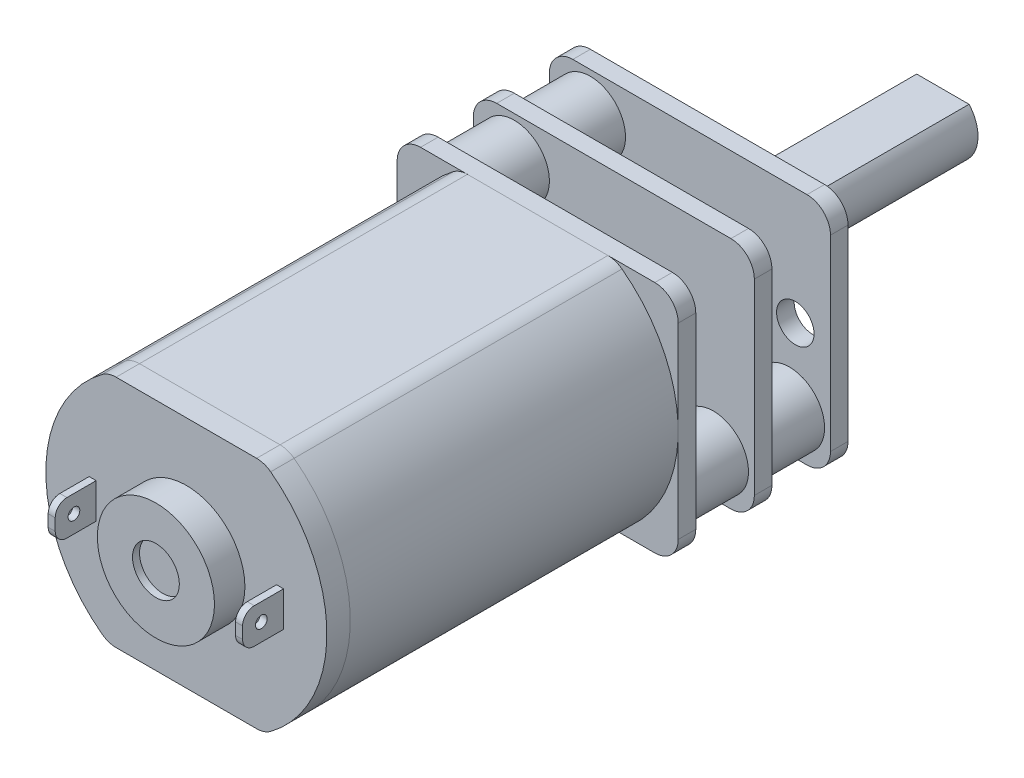
from build123d import *

# Parameters (mm, degrees)
BOSS_EXTRUDE1_DEPTH   = 14
FILLET1_R             = 1
BOSS_EXTRUDE2_DEPTH   = 1
SKETCH3_R             = 2.5
BOSS_EXTRUDE3_DEPTH   = 1.3
SKETCH4_R             = 1
CUT_EXTRUDE1_DEPTH    = 0.3
SKETCH5_W             = 0.3
SKETCH5_H             = 1.5
BOSS_EXTRUDE4_DEPTH   = 1.75
FILLET2_R             = 0.5
SKETCH6_R             = 0.25
CUT_EXTRUDE2_DEPTH    = 0.3
SKETCH7_R             = 0.25
CUT_EXTRUDE3_DEPTH    = 0.3
SKETCH8_W             = 12
SKETCH8_H             = 10
BOSS_EXTRUDE5_DEPTH   = 0.75
SKETCH9_W             = 12
SKETCH9_H             = 10
BOSS_EXTRUDE6_DEPTH   = 0.75
SKETCH10_W            = 12
SKETCH10_H            = 10
BOSS_EXTRUDE7_DEPTH   = 0.75
BOSS_EXTRUDE8_START   = -0.3
SKETCH11_R            = 1.5
BOSS_EXTRUDE8_DEPTH   = 6.2
BOSS_EXTRUDE8_2_DEPTH = 6.2
FILLET3_R             = 1
FILLET4_R             = 1
FILLET5_R             = 1
SKETCH12_R            = 2
BOSS_EXTRUDE9_DEPTH   = 0.8
SKETCH13_R            = 1.5
BOSS_EXTRUDE10_DEPTH  = 9.25
SKETCH14_W            = 9.25
SKETCH14_H            = 3
CUT_EXTRUDE4_DEPTH    = 0.5
CUT_EXTRUDE5_DEPTH    = 0.25
SKETCH16_R            = 1.5
CUT_EXTRUDE6_DEPTH    = 0.05
SKETCH17_R            = 0.8
CUT_EXTRUDE7_DEPTH    = 0.75


with BuildPart() as part:
    # Sketch1 → Boss-Extrude1 (new body)
    with BuildSketch(Plane.XY):
        with BuildLine():
            Line((-3.31662479, -5), (3.31662479, -5))
            ThreePointArc((3.31662479, -5), (6, 0), (3.31662479, 5))
            Line((3.31662479, 5), (-3.31662479, 5))
            ThreePointArc((-3.31662479, 5), (-6, 0), (-3.31662479, -5))
        make_face()
    extrude(amount=-BOSS_EXTRUDE1_DEPTH)

    # Fillet1
    fillet1_edges = [part.edges().sort_by_distance(p)[0] for p in [
        (3.31662479, -5, -7),
        (-3.31662479, -5, -7),
        (-3.31662479, 5, -7),
        (3.31662479, 5, -7),
    ]]
    fillet(fillet1_edges, radius=FILLET1_R)


with BuildPart() as body_2:
    # Sketch2 → Boss-Extrude2 (new body)
    with BuildSketch(Plane.XY):
        with BuildLine():
            Line((-3, -5), (3, -5))
            ThreePointArc((3, -5), (3.316227766, -4.948683298), (3.6, -4.8))
            ThreePointArc((3.6, -4.8), (6, 0), (3.6, 4.8))
            ThreePointArc((3.6, 4.8), (3.316227766, 4.948683298), (3, 5))
            Line((3, 5), (-3, 5))
            ThreePointArc((-3, 5), (-3.316227766, 4.948683298), (-3.6, 4.8))
            ThreePointArc((-3.6, 4.8), (-6, 0), (-3.6, -4.8))
            ThreePointArc((-3.6, -4.8), (-3.316227766, -4.948683298), (-3, -5))
        make_face()
    extrude(amount=BOSS_EXTRUDE2_DEPTH)

    # Sketch3 → Boss-Extrude3 (add)
    with BuildSketch(Plane.XY.offset(1)):
        Circle(SKETCH3_R)
    extrude(amount=BOSS_EXTRUDE3_DEPTH)

    # Sketch4 → Cut-Extrude1 (cut)
    with BuildSketch(Plane.XY.offset(2.3)):
        Circle(SKETCH4_R)
    extrude(amount=-CUT_EXTRUDE1_DEPTH, mode=Mode.SUBTRACT)

    # Sketch5 → Boss-Extrude4 (add)
    with BuildSketch(Plane.XY.offset(1)):
        with Locations((-4, 0)):
            Rectangle(SKETCH5_W, SKETCH5_H)
        with Locations((4, 0)):
            Rectangle(SKETCH5_W, SKETCH5_H)
    extrude(amount=BOSS_EXTRUDE4_DEPTH)

    # Fillet2
    fillet2_edges = [body_2.edges().sort_by_distance(p)[0] for p in [
        (-4, 0.75, 2.75),
        (-4, -0.75, 2.75),
        (4, 0.75, 2.75),
        (4, -0.75, 2.75),
    ]]
    fillet(fillet2_edges, radius=FILLET2_R)

    # Sketch6 → Cut-Extrude2 (cut)
    with BuildSketch(Plane.ZY.offset(4.15)):
        with Locations((1.95, 0)):
            Circle(SKETCH6_R)
    extrude(amount=-CUT_EXTRUDE2_DEPTH, mode=Mode.SUBTRACT)

    # Sketch7 → Cut-Extrude3 (cut)
    with BuildSketch(Plane(origin=(4.15, 0, 0), x_dir=(0, 0, -1), z_dir=(1, 0, 0))):
        with Locations((-1.95, 0)):
            Circle(SKETCH7_R)
    extrude(amount=-CUT_EXTRUDE3_DEPTH, mode=Mode.SUBTRACT)


with BuildPart() as body_3:
    # Sketch8 → Boss-Extrude5 (new body)
    with BuildSketch(Plane(origin=(0, 0, -14), x_dir=(-1, 0, 0), z_dir=(0, 0, -1))):
        Rectangle(SKETCH8_W, SKETCH8_H)
    extrude(amount=BOSS_EXTRUDE5_DEPTH)

    # Fillet5
    fillet5_edges = [body_3.edges().sort_by_distance(p)[0] for p in [
        (6, 5, -14.375),
        (-6, 5, -14.375),
        (-6, -5, -14.375),
        (6, -5, -14.375),
    ]]
    fillet(fillet5_edges, radius=FILLET5_R)


with BuildPart() as body_4:
    # Sketch9 → Boss-Extrude6 (new body)
    with BuildSketch(Plane(origin=(0, 0, -17.25), x_dir=(-1, 0, 0), z_dir=(0, 0, -1))):
        Rectangle(SKETCH9_W, SKETCH9_H)
    extrude(amount=BOSS_EXTRUDE6_DEPTH)

    # Fillet4
    fillet4_edges = [body_4.edges().sort_by_distance(p)[0] for p in [
        (-6, 5, -17.625),
        (-6, -5, -17.625),
        (6, -5, -17.625),
        (6, 5, -17.625),
    ]]
    fillet(fillet4_edges, radius=FILLET4_R)


with BuildPart() as body_5:
    # Sketch10 → Boss-Extrude7 (new body)
    with BuildSketch(Plane(origin=(0, 0, -20.5), x_dir=(-1, 0, 0), z_dir=(0, 0, -1))):
        Rectangle(SKETCH10_W, SKETCH10_H)
    extrude(amount=BOSS_EXTRUDE7_DEPTH)

    # Fillet3
    fillet3_edges = [body_5.edges().sort_by_distance(p)[0] for p in [
        (-6, -5, -20.875),
        (6, -5, -20.875),
        (6, 5, -20.875),
        (-6, 5, -20.875),
    ]]
    fillet(fillet3_edges, radius=FILLET3_R)

    # Sketch12 → Boss-Extrude9 (add)
    with BuildSketch(Plane(origin=(0, 0, -21.25), x_dir=(-1, 0, 0), z_dir=(0, 0, -1))):
        Circle(SKETCH12_R)
    extrude(amount=BOSS_EXTRUDE9_DEPTH)

    # Sketch13 → Boss-Extrude10 (add)
    with BuildSketch(Plane(origin=(0, 0, -22.05), x_dir=(-1, 0, 0), z_dir=(0, 0, -1))):
        Circle(SKETCH13_R)
    extrude(amount=BOSS_EXTRUDE10_DEPTH)

    # Sketch14 → Cut-Extrude4 (cut)
    with BuildSketch(Plane.ZX.offset(1.5)):
        with Locations((-26.675, 0)):
            Rectangle(SKETCH14_W, SKETCH14_H)
    extrude(amount=-CUT_EXTRUDE4_DEPTH, mode=Mode.SUBTRACT)

    # Sketch15 → Cut-Extrude5 (cut)
    with BuildSketch(Plane(origin=(0, 0, -21.25), x_dir=(-1, 0, 0), z_dir=(0, 0, -1))):
        with BuildLine():
            ThreePointArc((4.45, 4.736606875), (4.25, 4.75), (4.05, 4.736606875))
            Line((4.05, 4.736606875), (4.05, 3.65))
            ThreePointArc((4.05, 3.65), (3.991421356, 3.508578644), (3.85, 3.45))
            Line((3.85, 3.45), (2.763393125, 3.45))
            ThreePointArc((2.763393125, 3.45), (2.75, 3.25), (2.763393125, 3.05))
            Line((2.763393125, 3.05), (3.85, 3.05))
            ThreePointArc((3.85, 3.05), (3.991421356, 2.991421356), (4.05, 2.85))
            Line((4.05, 2.85), (4.05, 1.763393125))
            ThreePointArc((4.05, 1.763393125), (4.25, 1.75), (4.45, 1.763393125))
            Line((4.45, 1.763393125), (4.45, 2.85))
            ThreePointArc((4.45, 2.85), (4.508578644, 2.991421356), (4.65, 3.05))
            Line((4.65, 3.05), (5.736606875, 3.05))
            ThreePointArc((5.736606875, 3.05), (5.746647973, 3.149776031), (5.75, 3.25))
            ThreePointArc((5.75, 3.25), (5.746647973, 3.350223969), (5.736606875, 3.45))
            Line((5.736606875, 3.45), (4.65, 3.45))
            ThreePointArc((4.65, 3.45), (4.508578644, 3.508578644), (4.45, 3.65))
            Line((4.45, 3.65), (4.45, 4.736606875))
        make_face()
        with BuildLine():
            ThreePointArc((-4.05, -1.763393125), (-4.25, -1.75), (-4.45, -1.763393125))
            Line((-4.45, -1.763393125), (-4.45, -2.85))
            ThreePointArc((-4.45, -2.85), (-4.508578644, -2.991421356), (-4.65, -3.05))
            Line((-4.65, -3.05), (-5.736606875, -3.05))
            ThreePointArc((-5.736606875, -3.05), (-5.75, -3.25), (-5.736606875, -3.45))
            Line((-5.736606875, -3.45), (-4.65, -3.45))
            ThreePointArc((-4.65, -3.45), (-4.508578644, -3.508578644), (-4.45, -3.65))
            Line((-4.45, -3.65), (-4.45, -4.736606875))
            ThreePointArc((-4.45, -4.736606875), (-4.25, -4.75), (-4.05, -4.736606875))
            Line((-4.05, -4.736606875), (-4.05, -3.65))
            ThreePointArc((-4.05, -3.65), (-3.991421356, -3.508578644), (-3.85, -3.45))
            Line((-3.85, -3.45), (-2.763393125, -3.45))
            ThreePointArc((-2.763393125, -3.45), (-2.753352027, -3.350223969), (-2.75, -3.25))
            ThreePointArc((-2.75, -3.25), (-2.753352027, -3.149776031), (-2.763393125, -3.05))
            Line((-2.763393125, -3.05), (-3.85, -3.05))
            ThreePointArc((-3.85, -3.05), (-3.991421356, -2.991421356), (-4.05, -2.85))
            Line((-4.05, -2.85), (-4.05, -1.763393125))
        make_face()
    extrude(amount=-CUT_EXTRUDE5_DEPTH, mode=Mode.SUBTRACT)

    # Sketch16 → Cut-Extrude6 (cut)
    with BuildSketch(Plane(origin=(0, 0, -21.25), x_dir=(-1, 0, 0), z_dir=(0, 0, -1))):
        with Locations((4.25, 3.25)):
            Circle(SKETCH16_R)
        with Locations((-4.25, -3.25)):
            Circle(SKETCH16_R)
    extrude(amount=-CUT_EXTRUDE6_DEPTH, mode=Mode.SUBTRACT)

    # Sketch17 → Cut-Extrude7 (cut)
    with BuildSketch(Plane(origin=(0, 0, -21.25), x_dir=(-1, 0, 0), z_dir=(0, 0, -1))):
        with Locations((-4.5, 0)):
            Circle(SKETCH17_R)
        with Locations((4.5, 0)):
            Circle(SKETCH17_R)
    extrude(amount=-CUT_EXTRUDE7_DEPTH, mode=Mode.SUBTRACT)


with BuildPart() as body_6:
    # Sketch11 → Boss-Extrude8 (new body)
    with BuildSketch(Plane(origin=(0, 0, -21.25), x_dir=(-1, 0, 0), z_dir=(0, 0, -1)).offset(BOSS_EXTRUDE8_START)):
        with Locations((4.25, 3.25)):
            Circle(SKETCH11_R)
    extrude(amount=-BOSS_EXTRUDE8_DEPTH)


with BuildPart() as body_7:
    # Sketch11 → Boss-Extrude8 2 (new body)
    with BuildSketch(Plane(origin=(0, 0, -21.25), x_dir=(-1, 0, 0), z_dir=(0, 0, -1)).offset(BOSS_EXTRUDE8_START)):
        with Locations((-4.25, -3.25)):
            Circle(SKETCH11_R)
    extrude(amount=-BOSS_EXTRUDE8_2_DEPTH)


solid = Compound([part.part, body_2.part, body_3.part, body_4.part, body_5.part, body_6.part, body_7.part])
